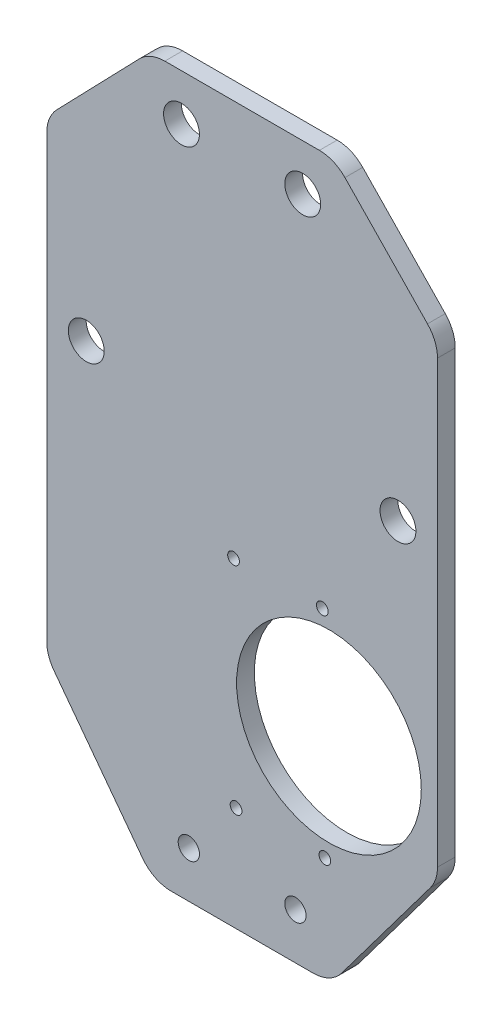
from build123d import *

# Parameters (mm, degrees)
SKETCH_1_R             = 26
SKETCH_1_R_2           = 3
SKETCH_1_R_3           = 5.05
EXTRUDE_1_DEPTH        = 5
FILLET_1_R             = 10
HOLE_WIZARD_M4_1_D     = 3.3
HOLE_WIZARD_M4_1_DEPTH = 10.1
HOLE_WIZARD_M4_1_TIP   = 0.991420021


with BuildPart() as part:
    # 草图1 → 凸台-拉伸1 (new body)
    with BuildSketch(Plane.XY):
        Polygon((-25, 0), (25, 0), (55, 40), (55, 171.5), (26, 201.5), (-26, 201.5), (-55, 171.5), (-55, 40), align=None)
        with Locations((24.438959159, 60)):
            Circle(SKETCH_1_R, mode=Mode.SUBTRACT)
        with Locations((15, 13)):
            Circle(SKETCH_1_R_2, mode=Mode.SUBTRACT)
        with Locations((-15, 13)):
            Circle(SKETCH_1_R_2, mode=Mode.SUBTRACT)
        with Locations((-17.0625, 188.499544236)):
            Circle(SKETCH_1_R_3, mode=Mode.SUBTRACT)
        with Locations((17.0625, 188.499544236)):
            Circle(SKETCH_1_R_3, mode=Mode.SUBTRACT)
        with Locations((-43.875, 122.217270257)):
            Circle(SKETCH_1_R_3, mode=Mode.SUBTRACT)
        with Locations((43.875, 122.217270257)):
            Circle(SKETCH_1_R_3, mode=Mode.SUBTRACT)
    extrude(amount=EXTRUDE_1_DEPTH)

    # 圆角1
    fillet_1_edges = [part.edges().sort_by_distance(p)[0] for p in [
        (-55, 40, 2.5),
        (-55, 171.5, 2.5),
        (-26, 201.5, 2.5),
        (26, 201.5, 2.5),
        (55, 171.5, 2.5),
        (55, 40, 2.5),
        (25, 0, 2.5),
        (-25, 0, 2.5),
    ]]
    fillet(fillet_1_edges, radius=FILLET_1_R)

    # M4 螺纹孔1
    with Locations(Plane(origin=(0, 0, 0), x_dir=(-1, 0, 0), z_dir=(0, 0, -1))):
        with Locations((2.413134666, 89.937895002), (-22.585154319, 90.23038054), (1.705319664, 29.442035657), (-23.292969321, 29.734521195)):
            Hole(HOLE_WIZARD_M4_1_D / 2, depth=HOLE_WIZARD_M4_1_DEPTH)
            with Locations((0, 0, -(HOLE_WIZARD_M4_1_DEPTH + HOLE_WIZARD_M4_1_TIP / 2))):  # 118° drill point
                Cone(0, HOLE_WIZARD_M4_1_D / 2, HOLE_WIZARD_M4_1_TIP, mode=Mode.SUBTRACT)


solid = part.part
